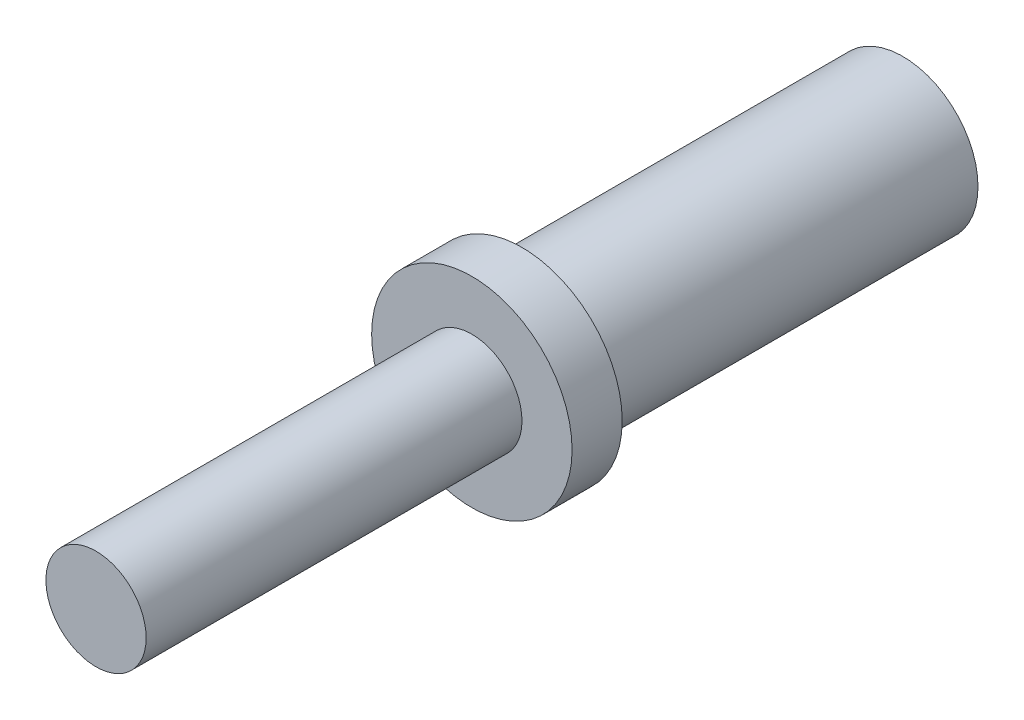
from build123d import *


with BuildPart() as part:
    # Sketch1 → Revolve1 (revolve)
    with BuildSketch(Plane(origin=(0, 0, 0), x_dir=(0, 0, -1), z_dir=(1, 0, 0))):
        Polygon((0, 0), (32.2, 0), (32.2, -3), (17, -3), (17, -4), (15, -4), (15, -2), (0, -2), align=None)
    revolve(axis=Axis((0, 0, 0), (0, 0, -1)))


solid = part.part
